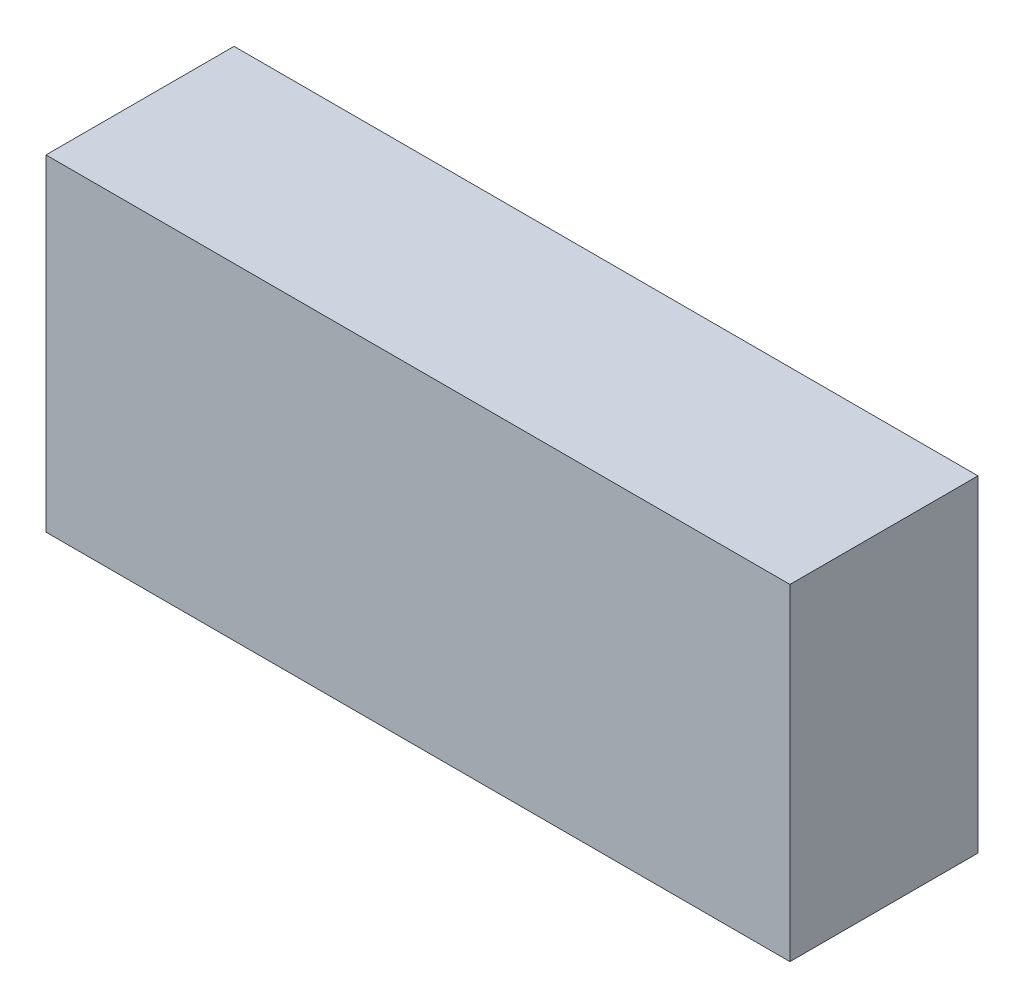
from build123d import *

# Parameters (mm, degrees)
SKETCH1_W           = 55.38
SKETCH1_H           = 24.32
BOSS_EXTRUDE1_DEPTH = 14


with BuildPart() as part:
    # Sketch1 → Boss-Extrude1 (new body)
    with BuildSketch(Plane.XY):
        with Locations((27.69, 12.16)):
            Rectangle(SKETCH1_W, SKETCH1_H)
    extrude(amount=BOSS_EXTRUDE1_DEPTH)


solid = part.part
